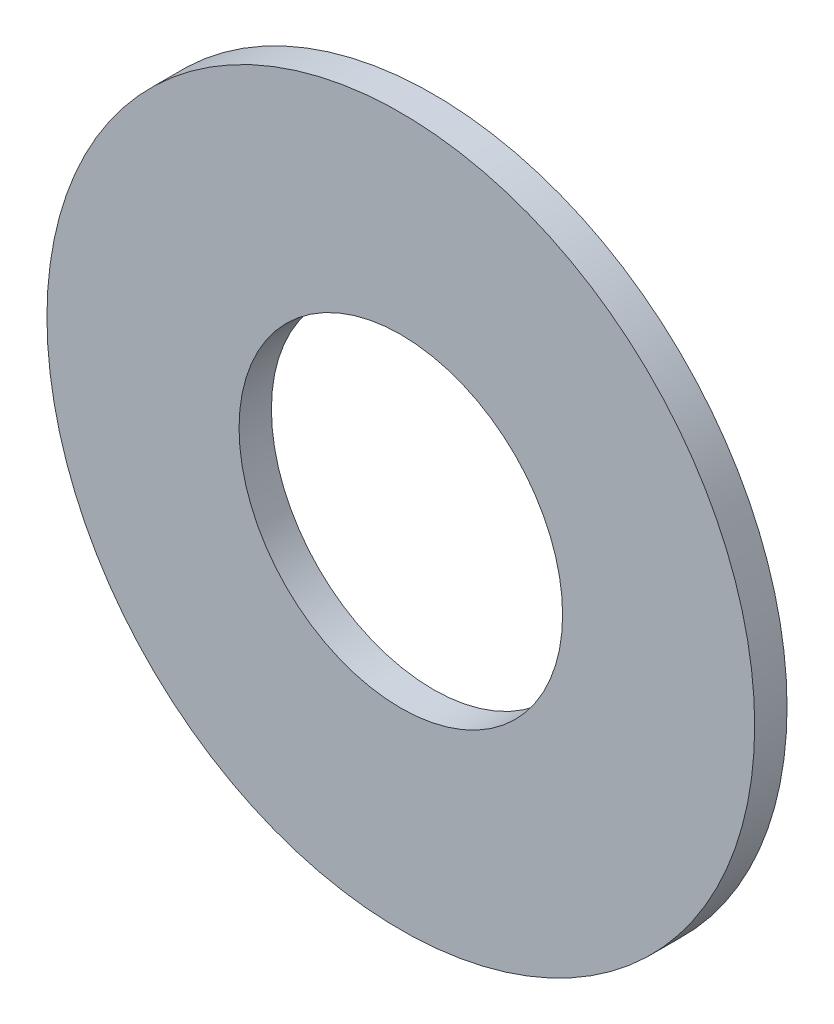
from build123d import *

# Parameters (mm, degrees)
SKETCH1_R      = 5.55625
SKETCH1_R_2    = 2.54
EXTRUDE1_DEPTH = 0.508


with BuildPart() as part:
    # Sketch1 → Extrude1 (new body)
    with BuildSketch(Plane.XY):
        Circle(SKETCH1_R)
        Circle(SKETCH1_R_2, mode=Mode.SUBTRACT)
    extrude(amount=-EXTRUDE1_DEPTH)


solid = part.part
